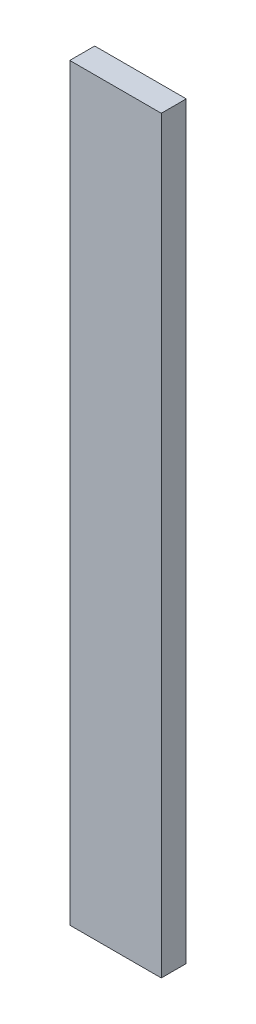
from build123d import *

# Parameters (mm, degrees)
SKETCH1_W           = 139.7
SKETCH1_H           = 38.1
BOSS_EXTRUDE1_DEPTH = 1143


with BuildPart() as part:
    # Sketch1 → Boss-Extrude1 (new body)
    with BuildSketch(Plane(origin=(0, 0, 0), x_dir=(1, 0, 0), z_dir=(0, 1, 0))):
        Rectangle(SKETCH1_W, SKETCH1_H)
    extrude(amount=BOSS_EXTRUDE1_DEPTH)


solid = part.part
